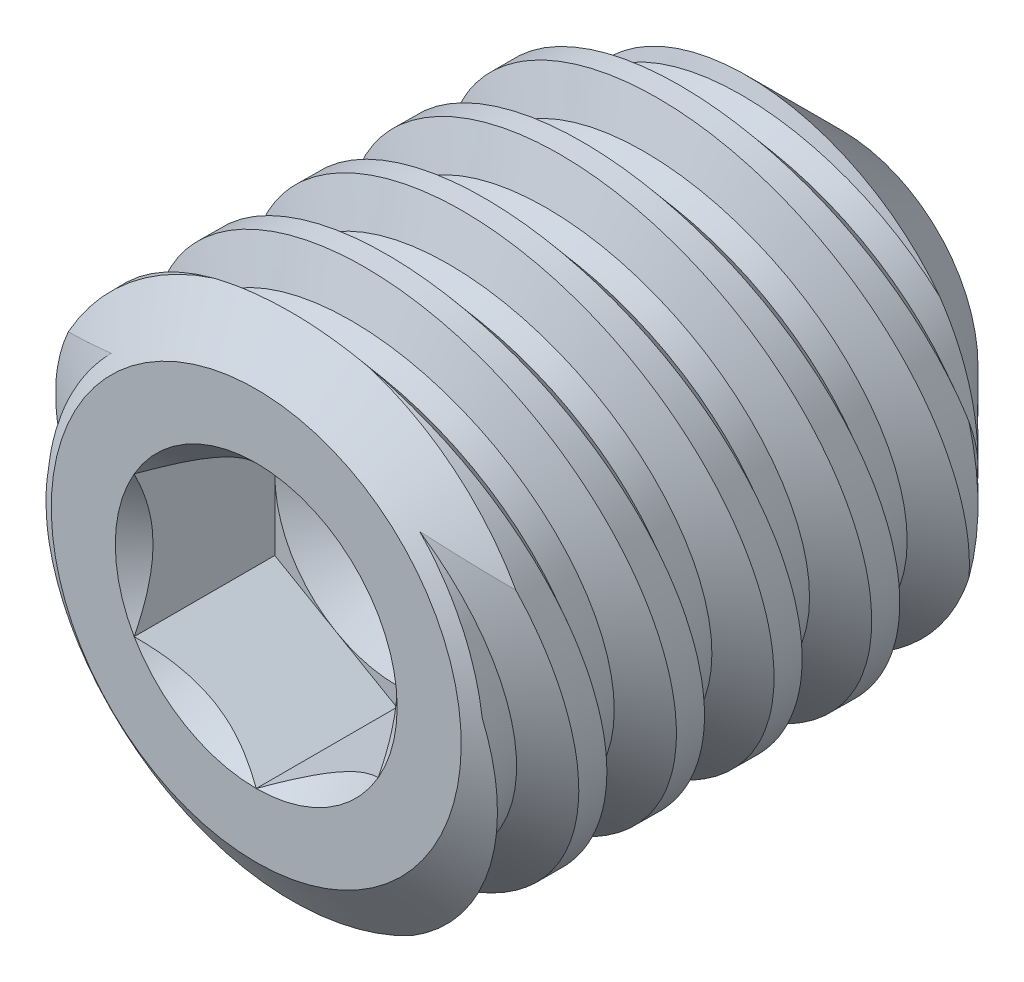
from build123d import *

# Parameters (mm, degrees)
LPATTERN1_COUNT     = 5
LPATTERN1_PITCH     = 0.79375
LPATTERN1_COL_COUNT = 2
LPATTERN1_COL_PITCH = 0.79375
CUT_EXTRUDE10_DEPTH = 1.143


with BuildPart() as part:
    # Sketch22 → Revolve1 (revolve)
    with BuildSketch(Plane(origin=(0, 0, 0), x_dir=(0, 0, -1), z_dir=(1, 0, 0)), mode=Mode.PRIVATE) as revolve1_sk:
        Polygon((-2.049304551, 0), (-2.049304551, 1.66624), (-1.757626099, 2.0828), (1.735295449, 2.0828), (2.713195449, 1.1049), (2.049304551, 0), align=None)
    revolve(revolve1_sk.sketch.rotate(Axis((0, 0, -2.049304551), (0, 0, -1)), 180), axis=Axis((0, 0, -2.049304551), (0, 0, -1)))

    # Sketch6 → Cut-Revolve8 (revolve, cut)
    with BuildSketch(Plane(origin=(0, 0, 0), x_dir=(0, 0, -1), z_dir=(1, 0, 0))):
        Polygon((1.103504251, 1.762908932), (0.908574043, 1.725765218), (0.584492784, 2.101371857), (1.266748512, 2.231374854), align=None)
    cut_revolve8 = revolve(axis=Axis((0, 0.162231854, -2.189813218), (0, -0.1871809179215621, 0.9823254572523515)), mode=Mode.SUBTRACT)

    # LPattern1: Cut-Revolve8 ×5
    with Locations(*[(0, 0, i * LPATTERN1_PITCH) for i in range(1, LPATTERN1_COUNT)]):
        add(cut_revolve8, mode=Mode.SUBTRACT)

    # LPattern1 col: Cut-Revolve8 ×2
    with Locations(*[(0, 0, -i * LPATTERN1_COL_PITCH) for i in range(1, LPATTERN1_COL_COUNT)]):
        add(cut_revolve8, mode=Mode.SUBTRACT)

    # Sketch23 → Cut-Extrude10 (cut)
    with BuildSketch(Plane.XY.offset(2.049304551)):
        Polygon((0, 1.14567944), (-0.9921875, 0.57283972), (-0.9921875, -0.57283972), (0, -1.14567944), (0.9921875, -0.57283972), (0.9921875, 0.57283972), align=None)
    extrude(amount=-CUT_EXTRUDE10_DEPTH, mode=Mode.SUBTRACT)

    # Cut-Extrude11 cone 1 section (through the dimple's axis) → Cut-Extrude11 (revolve, cut)
    with BuildSketch(Plane(origin=(0, 0, 2.049304551), x_dir=(0, -1, 0), z_dir=(1, 0, 0))):
        Polygon((0, 0), (1.14567944, 0), (0, 1.14567944), align=None)
    revolve(axis=Axis((0, 0, 2.049304551), (0, 0, -1)), mode=Mode.SUBTRACT)

    # Cut-Extrude12 cone 1 section (through the dimple's axis) → Cut-Extrude12 (revolve, cut)
    with BuildSketch(Plane(origin=(0, 0, 0.906304551), x_dir=(0, -1, 0), z_dir=(1, 0, 0))):
        Polygon((0, 0), (0.9921875, 0), (0, 0.596166395), align=None)
    revolve(axis=Axis((0, 0, 0.906304551), (0, 0, -1)), mode=Mode.SUBTRACT)


solid = part.part
